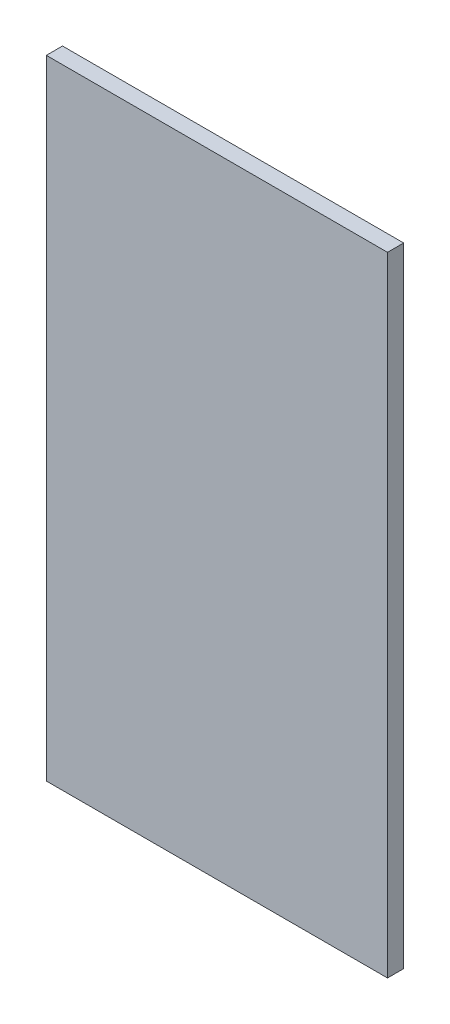
from build123d import *

# Parameters (mm, degrees)
SKETCH1_W           = 380
SKETCH1_H           = 700
BOSS_EXTRUDE1_DEPTH = 18


with BuildPart() as part:
    # Sketch1 → Boss-Extrude1 (new body)
    with BuildSketch(Plane.XY):
        with Locations((164.616725706, 317.523961047)):
            Rectangle(SKETCH1_W, SKETCH1_H)
    extrude(amount=BOSS_EXTRUDE1_DEPTH)


solid = part.part
